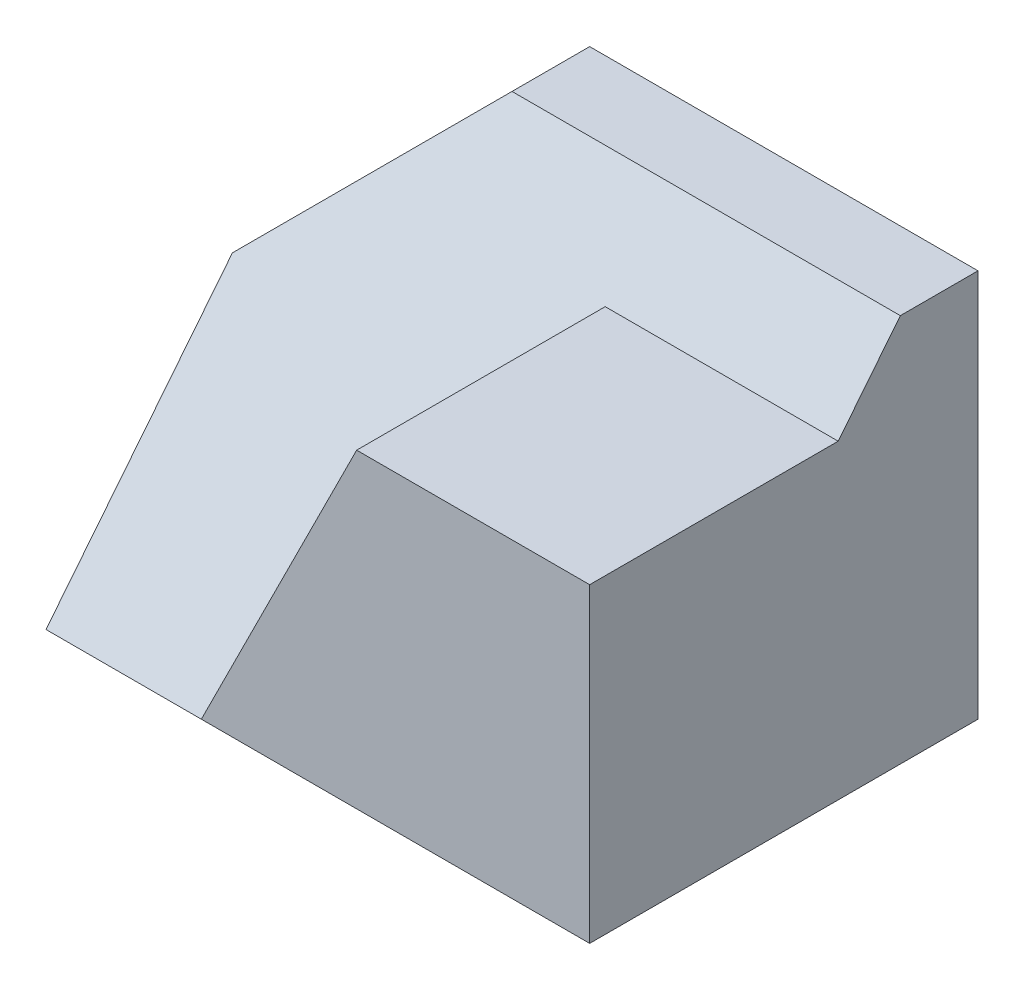
from build123d import *

# Parameters (mm, degrees)
SKETCH1_W            = 70
SKETCH1_H            = 50
BOSS_EXTRUDE1_DEPTH  = 50
CUT_EXTRUDE1_DEPTH   = 50
CUT_EXTRUDE2_DEPTH   = 81
CUT_EXTRUDE4_DEPTH   = 30
BOSS_EXTRUDE4_DEPTH  = 73
SKETCH7_W            = 70
SKETCH7_H            = 50
CUT_EXTRUDE5_DEPTH   = 73
SKETCH8_W            = 70
SKETCH8_H            = 50
CUT_EXTRUDE6_DEPTH   = 73
CUT_EXTRUDE7_DEPTH   = 73
CUT_EXTRUDE8_DEPTH   = 73
CUT_EXTRUDE9_DEPTH   = 73
CUT_EXTRUDE10_DEPTH  = 73
CUT_EXTRUDE11_DEPTH  = 73
CUT_EXTRUDE12_DEPTH  = 73
CUT_EXTRUDE13_DEPTH  = 73
CUT_EXTRUDE14_DEPTH  = 73
CUT_EXTRUDE15_DEPTH  = 73
CUT_EXTRUDE16_DEPTH  = 73
CUT_EXTRUDE17_DEPTH  = 73
BOSS_EXTRUDE6_DEPTH  = 40
BOSS_EXTRUDE9_DEPTH  = 20
CUT_EXTRUDE18_DEPTH  = 20
CUT_EXTRUDE19_DEPTH  = 20
CUT_EXTRUDE20_DEPTH  = 20
CUT_EXTRUDE21_DEPTH  = 20
CUT_EXTRUDE22_DEPTH  = 20
SKETCH28_W           = 25
SKETCH28_H           = 30
BOSS_EXTRUDE10_DEPTH = 20
CUT_EXTRUDE23_DEPTH  = 20
BOSS_EXTRUDE12_DEPTH = 10
CUT_EXTRUDE24_DEPTH  = 10
CUT_EXTRUDE25_DEPTH  = 10
CUT_EXTRUDE28_DEPTH  = 10
BOSS_EXTRUDE14_DEPTH = 35


with BuildPart() as part:
    # Sketch1 → Boss-Extrude1 (new body)
    with BuildSketch(Plane.XY):
        with Locations((35, 25)):
            Rectangle(SKETCH1_W, SKETCH1_H)
    extrude(amount=BOSS_EXTRUDE1_DEPTH)

    # Sketch2 → Cut-Extrude1 (cut)
    with BuildSketch(Plane.XY.offset(50)):
        Polygon((20, 50), (0, 30), (0, 50), align=None)
    extrude(amount=-CUT_EXTRUDE1_DEPTH, mode=Mode.SUBTRACT)

    # Sketch3 → Cut-Extrude2 (cut)
    with BuildSketch(Plane(origin=(70, 0, 0), x_dir=(0, 0, -1), z_dir=(1, 0, 0))):
        Polygon((-50, 40), (-20, 40), (-10, 50), (-50, 50), align=None)
    extrude(amount=-CUT_EXTRUDE2_DEPTH, mode=Mode.SUBTRACT)

    # Sketch4 → Cut-Extrude4 (cut)
    with BuildSketch(Plane.XY.offset(50)):
        Polygon((0, 0), (20, 0), (40, 40), (10, 40), (0, 30), align=None)
    extrude(amount=-CUT_EXTRUDE4_DEPTH, mode=Mode.SUBTRACT)

    # Sketch6 → Boss-Extrude4 (add)
    with BuildSketch(Plane(origin=(0, 24.390243902, 30.487804878), x_dir=(1, 0, 0), z_dir=(0, 0.624695048, 0.780868809))):
        Polygon((20, -31.234752378), (70, 32.796489997), (20, 32.796489997), align=None)
        Polygon((20, -31.234752378), (20, 32.796489997), (0, -31.234752378), align=None)
    extrude(amount=-BOSS_EXTRUDE4_DEPTH)

    # Sketch7 → Cut-Extrude5 (cut)
    with BuildSketch(Plane.XZ):
        with Locations((35, 25)):
            Rectangle(SKETCH7_W, SKETCH7_H)
    extrude(amount=CUT_EXTRUDE5_DEPTH, mode=Mode.SUBTRACT)

    # Sketch8 → Cut-Extrude6 (cut)
    with BuildSketch(Plane(origin=(0, 0, 0), x_dir=(-1, 0, 0), z_dir=(0, 0, -1))):
        with Locations((-35, 25)):
            Rectangle(SKETCH8_W, SKETCH8_H)
    extrude(amount=CUT_EXTRUDE6_DEPTH, mode=Mode.SUBTRACT)

    # Sketch9 → Cut-Extrude7 (cut)
    with BuildSketch(Plane.XY):
        Polygon((9.756097561, 0), (0, -40), (20, -40), (44.390243902, 0), align=None)
    extrude(amount=-CUT_EXTRUDE7_DEPTH, mode=Mode.SUBTRACT)

    # Sketch10 → Cut-Extrude8 (cut)
    with BuildSketch(Plane(origin=(32.359063313, -19.731136167, 0), x_dir=(0, 0, 1), z_dir=(-0.853796176, 0.520607424, 0))):
        Polygon((0, 23.109890541), (0, -23.739698546), (-11.485613867, -23.739698546), (-43.485613867, 23.109890541), align=None)
    extrude(amount=-CUT_EXTRUDE8_DEPTH, mode=Mode.SUBTRACT)

    # Sketch11 → Cut-Extrude9 (cut)
    with BuildSketch(Plane(origin=(0, 24.390243902, 30.487804878), x_dir=(1, 0, 0), z_dir=(0, 0.624695048, 0.780868809))):
        Polygon((0, -31.234752378), (20, -31.234752378), (70, 32.796489997), (20, 32.796489997), (0, 4.685212857), align=None)
    extrude(amount=CUT_EXTRUDE9_DEPTH, mode=Mode.SUBTRACT)

    # Sketch12 → Cut-Extrude10 (cut)
    with BuildSketch(Plane(origin=(-2.213114754, 1.229508197, -0.983606557), x_dir=(0.316569925, -0.17587218, -0.932122556), z_dir=(0.814821714, -0.45267873, 0.362142984))):
        Polygon((-22.511639083, 36.962823095), (-11.783436083, 53.42072243), (-22.511639083, 39.822720357), align=None)
    extrude(amount=-CUT_EXTRUDE10_DEPTH, mode=Mode.SUBTRACT)

    # Sketch13 → Cut-Extrude11 (cut)
    with BuildSketch(Plane(origin=(-7.126507887, 3.959171049, 20.983606557), x_dir=(-0.948569177, -0.058694552, -0.311081126), z_dir=(0.316569925, -0.17587218, -0.932122556))):
        Polygon((-18.055096359, 35.598308966), (-15.837888954, 33.59045957), (-16.59090279, 33.141654832), align=None)
    extrude(amount=-CUT_EXTRUDE11_DEPTH, mode=Mode.SUBTRACT)

    # Sketch14 → Cut-Extrude12 (cut)
    with BuildSketch(Plane(origin=(17.950733753, 32.311320755, 0), x_dir=(0.874157276, -0.485642931, 0), z_dir=(0.485642931, 0.874157276, 0))):
        Polygon((-11.501257989, -19.682539683), (-10.684144486, -20), (-11.501257989, -20), align=None)
    extrude(amount=-CUT_EXTRUDE12_DEPTH, mode=Mode.SUBTRACT)

    # Sketch15 → Cut-Extrude13 (cut)
    with BuildSketch(Plane(origin=(0, 0, 0), x_dir=(1, 0, 0), z_dir=(0, 1, 0))):
        Polygon((44.390243902, 43.485613867), (44.390243902, 0), (65.602738471, 43.485613867), align=None)
    extrude(amount=-CUT_EXTRUDE13_DEPTH, mode=Mode.SUBTRACT)

    # Sketch16 → Cut-Extrude14 (cut)
    with BuildSketch(Plane(origin=(0, -40, 0), x_dir=(1, 0, 0), z_dir=(0, 1, 0))):
        Polygon((20, 11.485613867), (20, 0), (0, 0), (2.241095389, 11.485613867), align=None)
    extrude(amount=-CUT_EXTRUDE14_DEPTH, mode=Mode.SUBTRACT)

    # Sketch17 → Cut-Extrude15 (cut)
    with BuildSketch(Plane(origin=(0, 0, 0), x_dir=(0.191510359, 0, -0.981490592), z_dir=(0.981490592, 0, 0.191510359))):
        Polygon((11.702214937, -40), (7.135496913, -45.602738471), (0, -40), align=None)
    extrude(amount=-CUT_EXTRUDE15_DEPTH, mode=Mode.SUBTRACT)

    # Sketch18 → Cut-Extrude16 (cut)
    with BuildSketch(Plane.ZY.offset(-20)):
        Polygon((-7.003423089, -45.602738471), (0, -40), (-11.485613867, -40), align=None)
    extrude(amount=-CUT_EXTRUDE16_DEPTH, mode=Mode.SUBTRACT)

    # Sketch19 → Cut-Extrude17 (cut)
    with BuildSketch(Plane(origin=(0, -24.390243902, 19.512195122), x_dir=(1, 0, 0), z_dir=(0, -0.780868809, 0.624695048))):
        Polygon((0, -33.956559528), (1.366521578, -33.956559528), (0, -24.987801902), align=None)
    extrude(amount=-CUT_EXTRUDE17_DEPTH, mode=Mode.SUBTRACT)

    # Sketch20 → Boss-Extrude6 (add)
    with BuildSketch(Plane.XY.offset(50)):
        Polygon((20, 0), (70, 0), (70, 40), (40, 40), align=None)
    extrude(amount=-BOSS_EXTRUDE6_DEPTH)

    # Sketch22 → Boss-Extrude9 (add)
    with BuildSketch(Plane.ZY):
        Polygon((20, 0), (50, 0), (20, 50), align=None)
    extrude(amount=-BOSS_EXTRUDE9_DEPTH)

    # Sketch23 → Cut-Extrude18 (cut)
    with BuildSketch(Plane(origin=(0, 24.390243902, 30.487804878), x_dir=(1, 0, 0), z_dir=(0, 0.624695048, 0.780868809))):
        Polygon((0, -31.234752378), (20, 32.796489997), (20, -31.234752378), align=None)
    extrude(amount=CUT_EXTRUDE18_DEPTH, mode=Mode.SUBTRACT)

    # Sketch24 → Cut-Extrude19 (cut)
    with BuildSketch(Plane(origin=(0, 24.390243902, 30.487804878), x_dir=(1, 0, 0), z_dir=(0, 0.624695048, 0.780868809))):
        Polygon((20, 32.796489997), (20, -31.234752378), (0, -31.234752378), (0, 0), align=None)
    extrude(amount=CUT_EXTRUDE19_DEPTH, mode=Mode.SUBTRACT)

    # Sketch25 → Cut-Extrude20 (cut)
    with BuildSketch(Plane(origin=(0, 0, 0), x_dir=(0.293651999, -0.139834285, -0.945629354), z_dir=(0.85377141, -0.406557814, 0.325246251))):
        Polygon((-35.72624266, 24.401635644), (-32.240755571, 22.020988264), (-21.149935654, 38.258970398), (-21.149935654, 52.103855338), align=None)
    extrude(amount=-CUT_EXTRUDE20_DEPTH, mode=Mode.SUBTRACT)

    # Sketch26 → Cut-Extrude21 (cut)
    with BuildSketch(Plane(origin=(0, 0, 20), x_dir=(-1, 0, 0), z_dir=(0, 0, -1))):
        Polygon((0, 30), (0, 37.5), (-7.5, 37.5), align=None)
    extrude(amount=-CUT_EXTRUDE21_DEPTH, mode=Mode.SUBTRACT)

    # Sketch27 → Cut-Extrude22 (cut)
    with BuildSketch(Plane(origin=(-2.564728872, 23.387884709, 35.967269174), x_dir=(-0.998217939, -0.032530406, -0.050027178), z_dir=(0.059673661, -0.54416696, -0.836852062))):
        Polygon((-2.569307534, 16.733584836), (-2.569307534, 29.52608638), (-18.788687646, 31.014533667), (-9.963436703, 16.446669873), align=None)
    extrude(amount=-CUT_EXTRUDE22_DEPTH, mode=Mode.SUBTRACT)

    # Sketch28 → Boss-Extrude10 (add)
    with BuildSketch(Plane.ZY):
        with Locations((12.5, 15)):
            Rectangle(SKETCH28_W, SKETCH28_H)
    extrude(amount=-BOSS_EXTRUDE10_DEPTH)

    # Sketch29 → Cut-Extrude23 (cut)
    with BuildSketch(Plane(origin=(0, 0, 20), x_dir=(-1, 0, 0), z_dir=(0, 0, -1))):
        Polygon((0, 48.224543081), (0, 50), (-16.19047619, 50), align=None)
    extrude(amount=-CUT_EXTRUDE23_DEPTH, mode=Mode.SUBTRACT)

    # Sketch30 → Boss-Extrude12 (add)
    with BuildSketch(Plane(origin=(0, 24.390243902, 30.487804878), x_dir=(1, 0, 0), z_dir=(0, 0.624695048, 0.780868809))):
        Polygon((20, 32.796489997), (0, 7.183993047), (19.391822061, 9.570105394), align=None)
    extrude(amount=-BOSS_EXTRUDE12_DEPTH)

    # Sketch31 → Cut-Extrude24 (cut)
    with BuildSketch(Plane(origin=(-2.564728872, 23.387884709, 35.967269174), x_dir=(-0.998217939, -0.032530406, -0.050027178), z_dir=(0.059673661, -0.54416696, -0.836852062))):
        Polygon((-9.678751188, 15.976738782), (-2.569307534, 7.787398424), (-2.569307534, 4.241162369), align=None)
    extrude(amount=-CUT_EXTRUDE24_DEPTH, mode=Mode.SUBTRACT)

    # Sketch32 → Cut-Extrude25 (cut)
    with BuildSketch(Plane(origin=(0, 37.5, 0), x_dir=(-1, 0, 0), z_dir=(0, -1, 0))):
        Polygon((-7.380952381, -27.5), (0, -26.973684211), (0, -27.5), align=None)
    extrude(amount=-CUT_EXTRUDE25_DEPTH, mode=Mode.SUBTRACT)

    # Sketch35 → Cut-Extrude28 (cut)
    with BuildSketch(Plane(origin=(0, 24.390243902, 30.487804878), x_dir=(1, 0, 0), z_dir=(0, 0.624695048, 0.780868809))):
        Polygon((70, 32.796489997), (70, -31.234752378), (0, -31.234752378), align=None)
    extrude(amount=CUT_EXTRUDE28_DEPTH, mode=Mode.SUBTRACT)

    # Sketch36 → Boss-Extrude14 (add)
    with BuildSketch(Plane.XY.offset(50)):
        Polygon((70, 0), (70, 16.007810594), (28.003905297, 16.007810594), (20, 0), align=None)
        Polygon((40, 40), (28.003905297, 16.007810594), (70, 16.007810594), (70, 40), align=None)
    extrude(amount=-BOSS_EXTRUDE14_DEPTH)


solid = part.part
